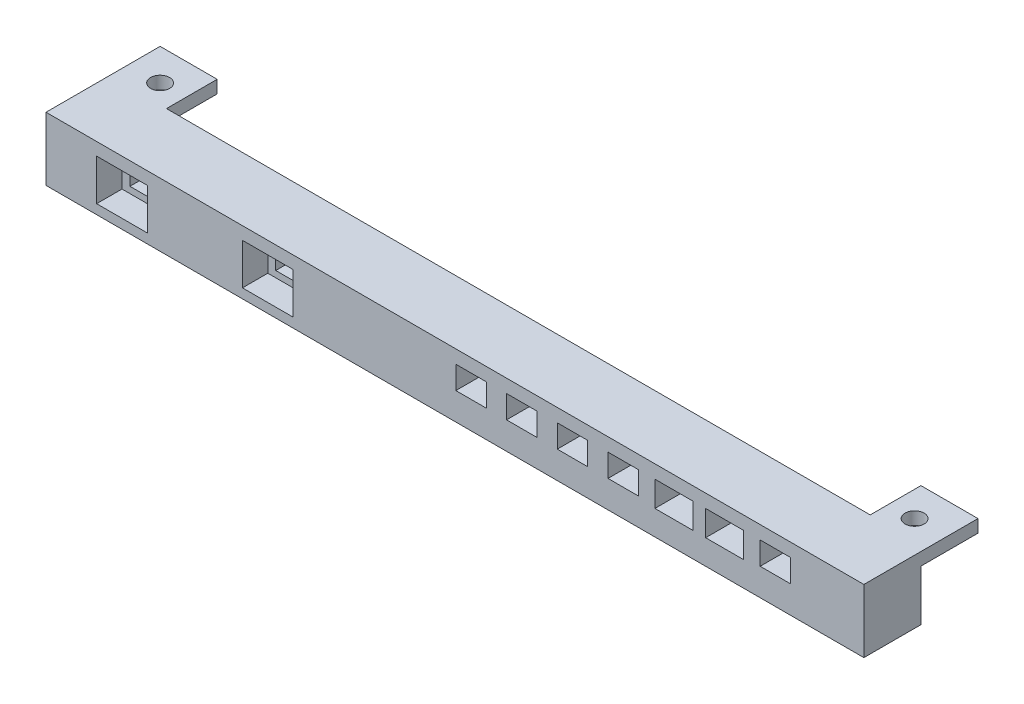
from build123d import *

# Parameters (mm, degrees)
SKETCH3_R           = 1.5
BOSS_EXTRUDE4_DEPTH = 2
SKETCH8_W           = 129
SKETCH8_H           = 9
BOSS_EXTRUDE5_DEPTH = 10
SKETCH10_W          = 5.5
SKETCH10_H          = 4.5
SKETCH10_W_2        = 4.80000148
SKETCH10_H_2        = 3.5999988
SKETCH10_H_3        = 3.597941299
SKETCH10_W_3        = 5.99999908
SKETCH10_H_4        = 4.00000054
CUT_EXTRUDE1_DEPTH  = 18
SKETCH11_W          = 8
SKETCH11_H          = 6.5
CUT_EXTRUDE2_DEPTH  = 4
SKETCH12_W          = 111
SKETCH12_H          = 8
CUT_EXTRUDE3_DEPTH  = 10


with BuildPart() as part:
    # Sketch3 → Boss-Extrude4 (new body)
    with BuildSketch(Plane(origin=(0, 0, 0), x_dir=(1, 0, 0), z_dir=(0, 1, 0))):
        Polygon((-64.5, -13), (64.5, -13), (64.5, 5), (54.5, 5), (54.5, -3), (-54.5, -3), (-54.5, 5), (-64.5, 5), align=None)
        with Locations((-59.5, 0)):
            Circle(SKETCH3_R, mode=Mode.SUBTRACT)
        with Locations((59.5, 0)):
            Circle(SKETCH3_R, mode=Mode.SUBTRACT)
    extrude(amount=BOSS_EXTRUDE4_DEPTH)

    # Sketch8 → Boss-Extrude5 (add)
    with BuildSketch(Plane(origin=(0, 2, 0), x_dir=(1, 0, 0), z_dir=(0, 1, 0))):
        with Locations((0, -8.5)):
            Rectangle(SKETCH8_W, SKETCH8_H)
    extrude(amount=-BOSS_EXTRUDE5_DEPTH)

    # Sketch10 → Cut-Extrude1 (cut)
    with BuildSketch(Plane.XY.offset(13)):
        with Locations((-52.513655094, -3.248549409)):
            Rectangle(SKETCH10_W, SKETCH10_H)
        with Locations((-29.513655374, -3.248549409)):
            Rectangle(SKETCH10_W, SKETCH10_H)
        with Locations((2.541347826, -1.898548299)):
            Rectangle(SKETCH10_W_2, SKETCH10_H_2)
        with Locations((10.541347066, -1.898548299)):
            Rectangle(SKETCH10_W_2, SKETCH10_H_2)
        with Locations((18.541346306, -1.898548299)):
            Rectangle(SKETCH10_W_2, SKETCH10_H_2)
        with Locations((26.541345546, -1.89957705)):
            Rectangle(SKETCH10_W_2, SKETCH10_H_3)
        with Locations((34.541344786, -2.098549169)):
            Rectangle(SKETCH10_W_3, SKETCH10_H_4)
        with Locations((42.541344026, -2.098549169)):
            Rectangle(SKETCH10_W_3, SKETCH10_H_4)
        with Locations((50.541343266, -1.898548299)):
            Rectangle(SKETCH10_W_2, SKETCH10_H_2)
    extrude(amount=-CUT_EXTRUDE1_DEPTH, mode=Mode.SUBTRACT)

    # Sketch11 → Cut-Extrude2 (cut)
    with BuildSketch(Plane.XY.offset(13)):
        with Locations((-52.513655094, -3.248549409)):
            Rectangle(SKETCH11_W, SKETCH11_H)
        with Locations((-29.513655374, -3.248549409)):
            Rectangle(SKETCH11_W, SKETCH11_H)
    extrude(amount=-CUT_EXTRUDE2_DEPTH, mode=Mode.SUBTRACT)

    # Sketch12 → Cut-Extrude3 (cut)
    with BuildSketch(Plane(origin=(0, 2, 0), x_dir=(1, 0, 0), z_dir=(0, 1, 0))):
        with Locations((0, 1)):
            Rectangle(SKETCH12_W, SKETCH12_H)
    extrude(amount=-CUT_EXTRUDE3_DEPTH, mode=Mode.SUBTRACT)


solid = part.part
